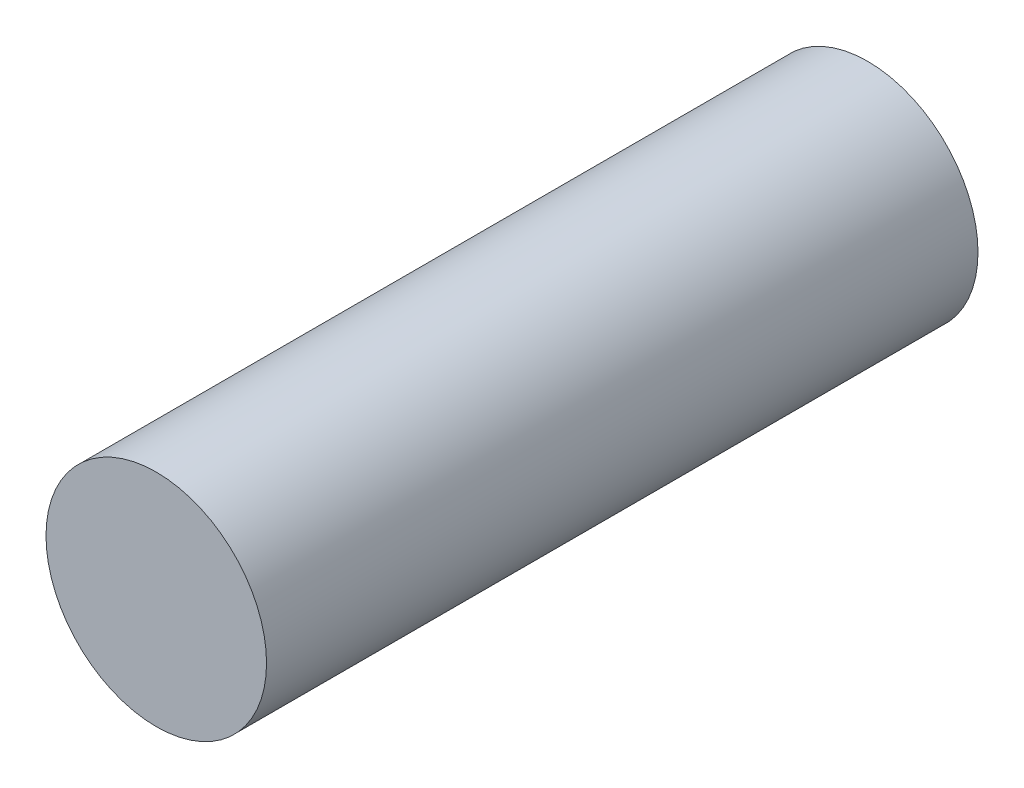
from build123d import *

# Parameters (mm, degrees)
SKETCH1_R           = 7.75
BOSS_EXTRUDE1_DEPTH = 50


with BuildPart() as part:
    # Sketch1 → Boss-Extrude1 (new body)
    with BuildSketch(Plane.XY):
        Circle(SKETCH1_R)
    extrude(amount=BOSS_EXTRUDE1_DEPTH)


solid = part.part
